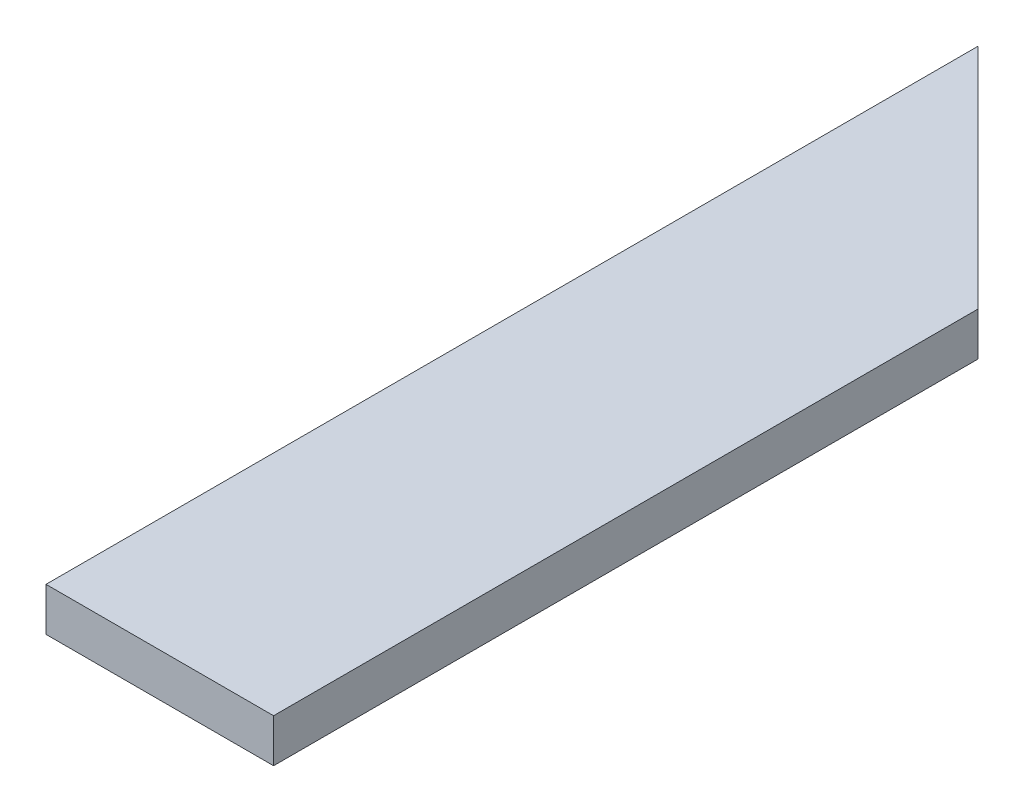
from build123d import *

# Parameters (mm, degrees)
EXTRUDE_1_DEPTH = 8


with BuildPart() as part:
    # 草图1 → 凸台-拉伸1 (new body)
    with BuildSketch(Plane(origin=(0, 0, 0), x_dir=(1, 0, 0), z_dir=(0, 1, 0))):
        Polygon((0, 0), (0, 42), (42, 0), (42, -130), (0, -130), align=None)
    extrude(amount=EXTRUDE_1_DEPTH)


solid = part.part
